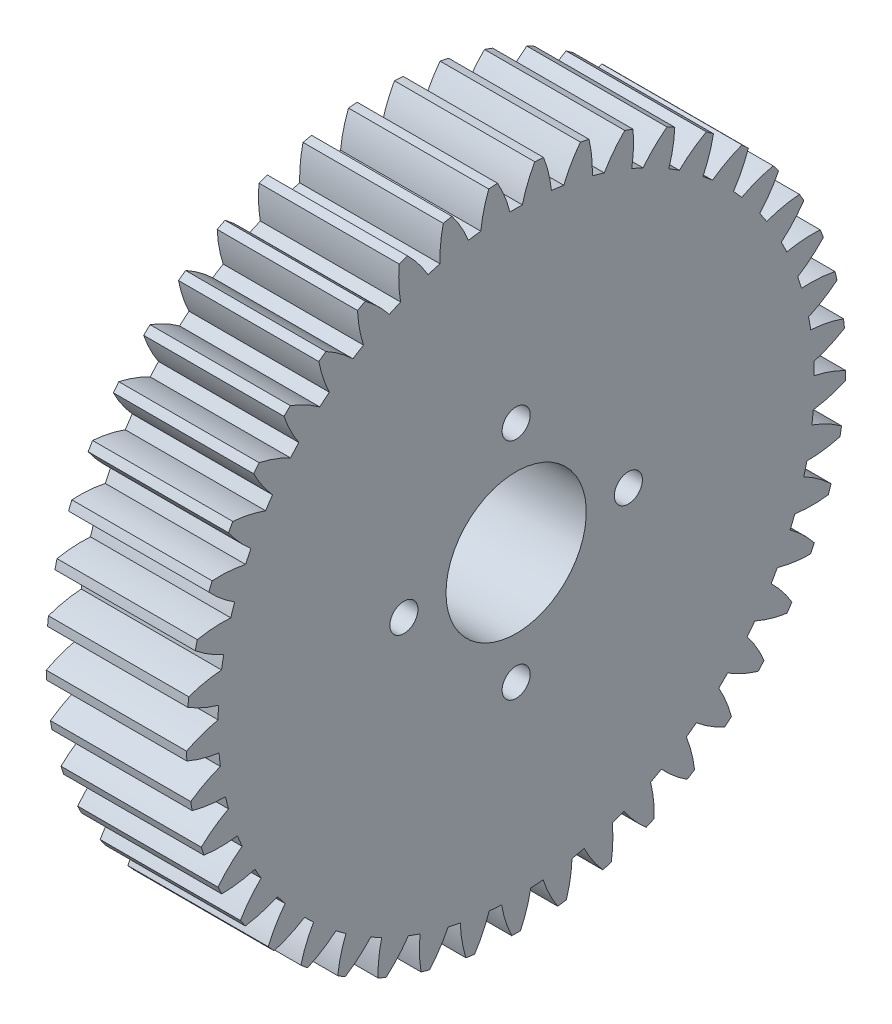
from build123d import *

# Parameters (mm, degrees)
BASPROSKE_W          = 10
BASPROSKE_H          = 23.5
TOOTHCUT_DEPTH       = 35.705907278
TEETHCUTS_COUNT      = 45
TEETHCUTS_ANGLE      = 352
BORSKE_R             = 5
BORE_DEPTH           = 50.0000508
D_GAGEMENT_M21_D     = 2
D_GAGEMENT_M21_DEPTH = 10


with BuildPart() as part:
    # BasProSke → Base-Revolve (revolve)
    with BuildSketch(Plane(origin=(0, 0, 0), x_dir=(1, 0, 0), z_dir=(0, 1, 0)), mode=Mode.PRIVATE) as base_revolve_sk:
        with Locations((5, 11.75)):
            Rectangle(BASPROSKE_W, BASPROSKE_H)
    revolve(base_revolve_sk.sketch.rotate(Axis((-10, 0, 0), (1, 0, 0)), 180), axis=Axis((-10, 0, 0), (1, 0, 0)))

    # TooCutSke → ToothCut (cut, through all)
    with BuildSketch(Plane(origin=(0, 0, 0), x_dir=(0, 0, -1), z_dir=(1, 0, 0))):
        with BuildLine():
            ThreePointArc((0.442593582, 21.244390128), (0, 21.249), (-0.442593582, 21.244390128))
            ThreePointArc((-0.442593582, 21.244390128), (-0.816027501, 22.396050003), (-1.340654493, 23.487168639))
            ThreePointArc((-1.340654493, 23.487168639), (0, 23.5254), (1.340654493, 23.487168639))
            ThreePointArc((1.340654493, 23.487168639), (0.816027501, 22.396050003), (0.442593582, 21.244390128))
        make_face()
    toothcut = extrude(amount=TOOTHCUT_DEPTH, mode=Mode.SUBTRACT)

    # TeethCuts: ToothCut ×45 about axis
    teethcuts_axis = Axis((-10, 0, 0), (1, 0, 0))
    for i in range(1, TEETHCUTS_COUNT):
        add(toothcut.rotate(teethcuts_axis, i * TEETHCUTS_ANGLE / (TEETHCUTS_COUNT - 1)), mode=Mode.SUBTRACT)

    # BorSke → Bore (cut, symmetric)
    with BuildSketch(Plane(origin=(0, 0, 0), x_dir=(0, 0, -1), z_dir=(1, 0, 0))):
        with Locations(Location((0, 0, 0), (0, 0, 180))):
            Circle(BORSKE_R)
    extrude(amount=BORE_DEPTH, both=True, mode=Mode.SUBTRACT)

    # Dégagement M21
    with Locations(Plane(origin=(10, 0, 0), x_dir=(0, 0, -1), z_dir=(1, 0, 0))):
        with Locations((0, 8), (8, 0), (0, -8), (-8, 0), (0, 0)):
            Hole(D_GAGEMENT_M21_D / 2, depth=D_GAGEMENT_M21_DEPTH)


solid = part.part
